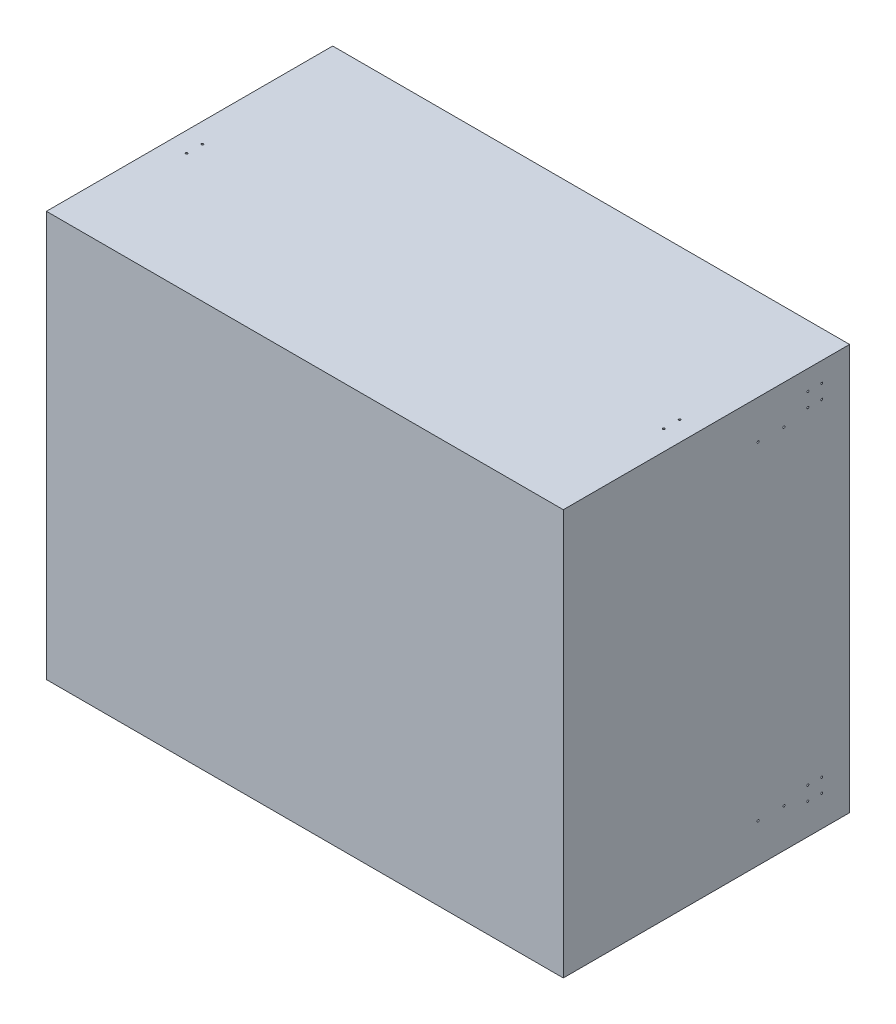
from build123d import *

# Parameters (mm, degrees)
SKETCH1_W               = 1300
SKETCH1_H               = 1020
BOSS_EXTRUDE2_DEPTH     = 720
SKETCH3_W               = 1280
SKETCH3_H               = 1000
CUT_EXTRUDE1_DEPTH      = 710
SKETCH4_R               = 2.5
CUT_EXTRUDE2_DEPTH      = 651
CUT_EXTRUDE2_DEPTH_BACK = 651
SKETCH6_R               = 2.5
CUT_EXTRUDE5_DEPTH      = 3326.5
SKETCH7_R               = 2.5
CUT_EXTRUDE6_DEPTH      = 652
CUT_EXTRUDE6_DEPTH_BACK = 886


with BuildPart() as part:
    # Sketch1 → Boss-Extrude2 (new body)
    with BuildSketch(Plane.XY):
        Rectangle(SKETCH1_W, SKETCH1_H)
    extrude(amount=BOSS_EXTRUDE2_DEPTH)

    # Sketch3 → Cut-Extrude1 (cut)
    with BuildSketch(Plane.XY):
        Rectangle(SKETCH3_W, SKETCH3_H)
    extrude(amount=CUT_EXTRUDE1_DEPTH, mode=Mode.SUBTRACT)

    # Sketch4 → Cut-Extrude2 (cut, two sides)
    with BuildSketch(Plane(origin=(0, 0, 0), x_dir=(0, 0, -1), z_dir=(1, 0, 0))) as cut_extrude2_sk:
        with Locations((-70, 460)):
            Circle(SKETCH4_R)
        with Locations((-105, 460)):
            Circle(SKETCH4_R)
        with Locations((-105, 425)):
            Circle(SKETCH4_R)
        with Locations((-70, 425)):
            Circle(SKETCH4_R)
        with Locations((-105, -432.5)):
            Circle(SKETCH4_R)
        with Locations((-105, -397.5)):
            Circle(SKETCH4_R)
        with Locations((-70, -397.5)):
            Circle(SKETCH4_R)
        with Locations((-70, -432.5)):
            Circle(SKETCH4_R)
    extrude(amount=CUT_EXTRUDE2_DEPTH, mode=Mode.SUBTRACT)
    extrude(cut_extrude2_sk.sketch, amount=-CUT_EXTRUDE2_DEPTH_BACK, mode=Mode.SUBTRACT)

    # Sketch6 → Cut-Extrude5 (cut)
    with BuildSketch(Plane(origin=(650, 0, 0), x_dir=(0, 0, -1), z_dir=(1, 0, 0))):
        with Locations((-105, 460)):
            Circle(SKETCH6_R)
        with Locations((-230, 412.5)):
            Circle(SKETCH6_R)
        with Locations((-165, 412.5)):
            Circle(SKETCH6_R)
        with Locations((-165, -412.5)):
            Circle(SKETCH6_R)
        with Locations((-230, -412.5)):
            Circle(SKETCH6_R)
    extrude(amount=-CUT_EXTRUDE5_DEPTH, mode=Mode.SUBTRACT)

    # Sketch7 → Cut-Extrude6 (cut, two sides)
    with BuildSketch(Plane(origin=(0, 0, 0), x_dir=(1, 0, 0), z_dir=(0, 1, 0))) as cut_extrude6_sk:
        with Locations((600, -417.5)):
            Circle(SKETCH7_R)
        with Locations((600, -377.5)):
            Circle(SKETCH7_R)
        with Locations((-600, -417.5)):
            Circle(SKETCH7_R)
        with Locations((-600, -377.5)):
            Circle(SKETCH7_R)
    extrude(amount=CUT_EXTRUDE6_DEPTH, mode=Mode.SUBTRACT)
    extrude(cut_extrude6_sk.sketch, amount=-CUT_EXTRUDE6_DEPTH_BACK, mode=Mode.SUBTRACT)


solid = part.part
